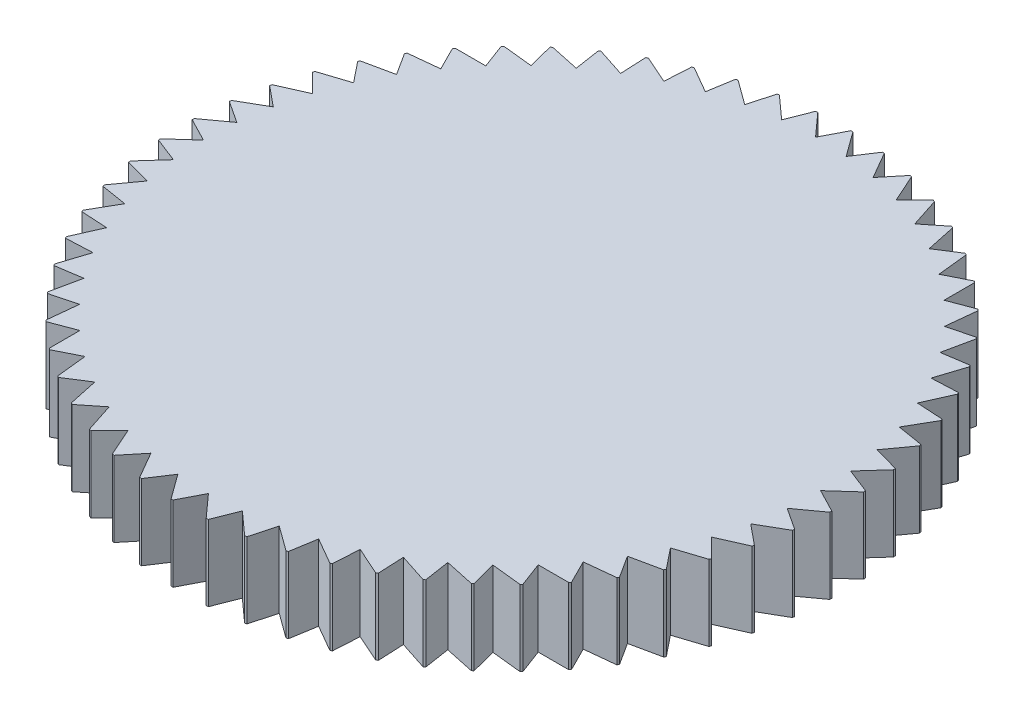
from build123d import *

# Parameters (mm, degrees)
Y_KSEKLIK_EKSTR_ZYON1_DEPTH = 3


with BuildPart() as part:
    # Çizim1 → Yükseklik-Ekstrüzyon1 (new body)
    with BuildSketch(Plane(origin=(0, 0, 0), x_dir=(1, 0, 0), z_dir=(0, 1, 0))):
        with BuildLine():
            ThreePointArc((-9.087504767, -9.407638232), (-9.059200833, -9.43489694), (-9.030815135, -9.462070492))
            Line((-9.030815135, -9.462070492), (-8.054356498, -9.094039392))
            Line((-8.054356498, -9.094039392), (-8.054356498, -10.306005114))
            ThreePointArc((-8.054356498, -10.306005114), (-8.023358305, -10.330155929), (-7.992287697, -10.354213508))
            Line((-7.992287697, -10.354213508), (-7.059647927, -9.8861308))
            Line((-7.059647927, -9.8861308), (-6.932963013, -11.091457247))
            ThreePointArc((-6.932963013, -11.091457247), (-6.899610184, -11.112235567), (-6.866195083, -11.132913594))
            Line((-6.866195083, -11.132913594), (-5.987592377, -10.56990769))
            Line((-5.987592377, -10.56990769), (-5.735610535, -11.755389053))
            ThreePointArc((-5.735610535, -11.755389053), (-5.70026849, -11.772567228), (-5.664874998, -11.789639149))
            Line((-5.664874998, -11.789639149), (-4.849935512, -11.13787846))
            Line((-4.849935512, -11.13787846), (-4.475417507, -12.290526357))
            ThreePointArc((-4.475417507, -12.290526357), (-4.438473462, -12.303916178), (-4.401489357, -12.31719495))
            Line((-4.401489357, -12.31719495), (-3.659141738, -11.583820302))
            Line((-3.659141738, -11.583820302), (-3.166190869, -12.691006082))
            ThreePointArc((-3.166190869, -12.691006082), (-3.12804959, -12.700460848), (-3.089880078, -12.709800986))
            Line((-3.089880078, -12.709800986), (-2.428257642, -11.902847385))
            Line((-2.428257642, -11.902847385), (-1.822274781, -12.952440489))
            ThreePointArc((-1.822274781, -12.952440489), (-1.783354152, -12.957856612), (-1.744417426, -12.963155783))
            Line((-1.744417426, -12.963155783), (-1.170769047, -12.091464382))
            Line((-1.170769047, -12.091464382), (-0.458393469, -13.071965247))
            ThreePointArc((-0.458393469, -13.071965247), (-0.419119912, -13.073283386), (-0.379842572, -13.074483532))
            Line((-0.379842572, -13.074483532), (0.099546739, -12.147604764))
            Line((0.099546739, -12.147604764), (0.910510097, -13.048270819))
            ThreePointArc((0.910510097, -13.048270819), (0.949706293, -13.045476532), (0.988893917, -13.042564503))
            Line((0.988893917, -13.042564503), (1.36877187, -12.070653446))
            Line((1.36877187, -12.070653446), (2.269437925, -12.881616805))
            ThreePointArc((2.269437925, -12.881616805), (2.308127317, -12.874740708), (2.346795877, -12.867748409))
            Line((2.346795877, -12.867748409), (2.62300045, -11.861453524))
            Line((2.62300045, -11.861453524), (3.603501315, -12.573829101))
            ThreePointArc((3.603501315, -12.573829101), (3.641260015, -12.562946529), (3.67898585, -12.55195057))
            Line((3.67898585, -12.55195057), (3.848490888, -11.522297034))
            Line((3.848490888, -11.522297034), (4.898083992, -12.128279895))
            ThreePointArc((4.898083992, -12.128279895), (4.934498307, -12.11351008), (4.970868085, -12.098630934))
            Line((4.970868085, -12.098630934), (5.031816454, -11.056899847))
            Line((5.031816454, -11.056899847), (6.139002234, -11.549850716))
            ThreePointArc((6.139002234, -11.549850716), (6.173673202, -11.531355479), (6.208288449, -11.512756166))
            Line((6.208288449, -11.512756166), (6.160012387, -10.470360951))
            Line((6.160012387, -10.470360951), (7.312660284, -10.844878956))
            ThreePointArc((7.312660284, -10.844878956), (7.345208042, -10.822860935), (7.377689505, -10.800745232))
            Line((7.377689505, -10.800745232), (7.220717935, -9.76910659))
            Line((7.220717935, -9.76910659), (8.406199298, -10.021088432))
            ThreePointArc((8.406199298, -10.021088432), (8.436267245, -9.995788861), (8.466259051, -9.970399073))
            Line((8.466259051, -9.970399073), (8.202311786, -8.960819852))
            Line((8.202311786, -8.960819852), (9.407638232, -9.087504767))
            ThreePointArc((9.407638232, -9.087504767), (9.43489694, -9.059200833), (9.462070492, -9.030815135))
            Line((9.462070492, -9.030815135), (9.094039392, -8.054356498))
            Line((9.094039392, -8.054356498), (10.306005114, -8.054356498))
            ThreePointArc((10.306005114, -8.054356498), (10.330155929, -8.023358305), (10.354213508, -7.992287697))
            Line((10.354213508, -7.992287697), (9.8861308, -7.059647927))
            Line((9.8861308, -7.059647927), (11.091457247, -6.932963013))
            ThreePointArc((11.091457247, -6.932963013), (11.112235567, -6.899610184), (11.132913594, -6.866195083))
            Line((11.132913594, -6.866195083), (10.56990769, -5.987592377))
            Line((10.56990769, -5.987592377), (11.755389053, -5.735610535))
            ThreePointArc((11.755389053, -5.735610535), (11.772567228, -5.70026849), (11.789639149, -5.664874998))
            Line((11.789639149, -5.664874998), (11.13787846, -4.849935512))
            Line((11.13787846, -4.849935512), (12.290526357, -4.475417507))
            ThreePointArc((12.290526357, -4.475417507), (12.303916178, -4.438473462), (12.31719495, -4.401489357))
            Line((12.31719495, -4.401489357), (11.583820302, -3.659141738))
            Line((11.583820302, -3.659141738), (12.691006082, -3.166190869))
            ThreePointArc((12.691006082, -3.166190869), (12.700460848, -3.12804959), (12.709800986, -3.089880078))
            Line((12.709800986, -3.089880078), (11.902847385, -2.428257642))
            Line((11.902847385, -2.428257642), (12.952440489, -1.822274781))
            ThreePointArc((12.952440489, -1.822274781), (12.957856612, -1.783354152), (12.963155783, -1.744417426))
            Line((12.963155783, -1.744417426), (12.091464382, -1.170769047))
            Line((12.091464382, -1.170769047), (13.071965247, -0.458393469))
            ThreePointArc((13.071965247, -0.458393469), (13.073283386, -0.419119912), (13.074483532, -0.379842572))
            Line((13.074483532, -0.379842572), (12.147604764, 0.099546739))
            Line((12.147604764, 0.099546739), (13.048270819, 0.910510097))
            ThreePointArc((13.048270819, 0.910510097), (13.045476532, 0.949706293), (13.042564503, 0.988893917))
            Line((13.042564503, 0.988893917), (12.070653446, 1.36877187))
            Line((12.070653446, 1.36877187), (12.881616805, 2.269437925))
            ThreePointArc((12.881616805, 2.269437925), (12.874740708, 2.308127317), (12.867748409, 2.346795877))
            Line((12.867748409, 2.346795877), (11.861453524, 2.62300045))
            Line((11.861453524, 2.62300045), (12.573829101, 3.603501315))
            ThreePointArc((12.573829101, 3.603501315), (12.562946529, 3.641260015), (12.55195057, 3.67898585))
            Line((12.55195057, 3.67898585), (11.522297034, 3.848490888))
            Line((11.522297034, 3.848490888), (12.128279895, 4.898083992))
            ThreePointArc((12.128279895, 4.898083992), (12.11351008, 4.934498307), (12.098630934, 4.970868085))
            Line((12.098630934, 4.970868085), (11.056899847, 5.031816454))
            Line((11.056899847, 5.031816454), (11.549850716, 6.139002234))
            ThreePointArc((11.549850716, 6.139002234), (11.531355479, 6.173673202), (11.512756166, 6.208288449))
            Line((11.512756166, 6.208288449), (10.470360951, 6.160012387))
            Line((10.470360951, 6.160012387), (10.844878956, 7.312660284))
            ThreePointArc((10.844878956, 7.312660284), (10.822860935, 7.345208042), (10.800745232, 7.377689505))
            Line((10.800745232, 7.377689505), (9.76910659, 7.220717935))
            Line((9.76910659, 7.220717935), (10.021088432, 8.406199298))
            ThreePointArc((10.021088432, 8.406199298), (9.995788861, 8.436267245), (9.970399073, 8.466259051))
            Line((9.970399073, 8.466259051), (8.960819852, 8.202311786))
            Line((8.960819852, 8.202311786), (9.087504767, 9.407638232))
            ThreePointArc((9.087504767, 9.407638232), (9.059200833, 9.43489694), (9.030815135, 9.462070492))
            Line((9.030815135, 9.462070492), (8.054356498, 9.094039392))
            Line((8.054356498, 9.094039392), (8.054356498, 10.306005114))
            ThreePointArc((8.054356498, 10.306005114), (8.023358305, 10.330155929), (7.992287697, 10.354213508))
            Line((7.992287697, 10.354213508), (7.059647927, 9.8861308))
            Line((7.059647927, 9.8861308), (6.932963013, 11.091457247))
            ThreePointArc((6.932963013, 11.091457247), (6.899610184, 11.112235567), (6.866195083, 11.132913594))
            Line((6.866195083, 11.132913594), (5.987592377, 10.56990769))
            Line((5.987592377, 10.56990769), (5.735610535, 11.755389053))
            ThreePointArc((5.735610535, 11.755389053), (5.70026849, 11.772567228), (5.664874998, 11.789639149))
            Line((5.664874998, 11.789639149), (4.849935512, 11.13787846))
            Line((4.849935512, 11.13787846), (4.475417507, 12.290526357))
            ThreePointArc((4.475417507, 12.290526357), (4.438473462, 12.303916178), (4.401489357, 12.31719495))
            Line((4.401489357, 12.31719495), (3.659141738, 11.583820302))
            Line((3.659141738, 11.583820302), (3.166190869, 12.691006082))
            ThreePointArc((3.166190869, 12.691006082), (3.12804959, 12.700460848), (3.089880078, 12.709800986))
            Line((3.089880078, 12.709800986), (2.428257642, 11.902847385))
            Line((2.428257642, 11.902847385), (1.822274781, 12.952440489))
            ThreePointArc((1.822274781, 12.952440489), (1.783354152, 12.957856612), (1.744417426, 12.963155783))
            Line((1.744417426, 12.963155783), (1.170769047, 12.091464382))
            Line((1.170769047, 12.091464382), (0.458393469, 13.071965247))
            ThreePointArc((0.458393469, 13.071965247), (0.419119912, 13.073283386), (0.379842572, 13.074483532))
            Line((0.379842572, 13.074483532), (-0.099546739, 12.147604764))
            Line((-0.099546739, 12.147604764), (-0.910510097, 13.048270819))
            ThreePointArc((-0.910510097, 13.048270819), (-0.949706293, 13.045476532), (-0.988893917, 13.042564503))
            Line((-0.988893917, 13.042564503), (-1.36877187, 12.070653446))
            Line((-1.36877187, 12.070653446), (-2.269437925, 12.881616805))
            ThreePointArc((-2.269437925, 12.881616805), (-2.308127317, 12.874740708), (-2.346795877, 12.867748409))
            Line((-2.346795877, 12.867748409), (-2.62300045, 11.861453524))
            Line((-2.62300045, 11.861453524), (-3.603501315, 12.573829101))
            ThreePointArc((-3.603501315, 12.573829101), (-3.641260015, 12.562946529), (-3.67898585, 12.55195057))
            Line((-3.67898585, 12.55195057), (-3.848490888, 11.522297034))
            Line((-3.848490888, 11.522297034), (-4.898083992, 12.128279895))
            ThreePointArc((-4.898083992, 12.128279895), (-4.934498307, 12.11351008), (-4.970868085, 12.098630934))
            Line((-4.970868085, 12.098630934), (-5.031816454, 11.056899847))
            Line((-5.031816454, 11.056899847), (-6.139002234, 11.549850716))
            ThreePointArc((-6.139002234, 11.549850716), (-6.173673202, 11.531355479), (-6.208288449, 11.512756166))
            Line((-6.208288449, 11.512756166), (-6.160012387, 10.470360951))
            Line((-6.160012387, 10.470360951), (-7.312660284, 10.844878956))
            ThreePointArc((-7.312660284, 10.844878956), (-7.345208042, 10.822860935), (-7.377689505, 10.800745232))
            Line((-7.377689505, 10.800745232), (-7.220717935, 9.76910659))
            Line((-7.220717935, 9.76910659), (-8.406199298, 10.021088432))
            ThreePointArc((-8.406199298, 10.021088432), (-8.436267245, 9.995788861), (-8.466259051, 9.970399073))
            Line((-8.466259051, 9.970399073), (-8.202311786, 8.960819852))
            Line((-8.202311786, 8.960819852), (-9.407638232, 9.087504767))
            ThreePointArc((-9.407638232, 9.087504767), (-9.43489694, 9.059200833), (-9.462070492, 9.030815135))
            Line((-9.462070492, 9.030815135), (-9.094039392, 8.054356498))
            Line((-9.094039392, 8.054356498), (-10.306005114, 8.054356498))
            ThreePointArc((-10.306005114, 8.054356498), (-10.330155929, 8.023358305), (-10.354213508, 7.992287697))
            Line((-10.354213508, 7.992287697), (-9.8861308, 7.059647927))
            Line((-9.8861308, 7.059647927), (-11.091457247, 6.932963013))
            ThreePointArc((-11.091457247, 6.932963013), (-11.112235567, 6.899610184), (-11.132913594, 6.866195083))
            Line((-11.132913594, 6.866195083), (-10.56990769, 5.987592377))
            Line((-10.56990769, 5.987592377), (-11.755389053, 5.735610535))
            ThreePointArc((-11.755389053, 5.735610535), (-11.772567228, 5.70026849), (-11.789639149, 5.664874998))
            Line((-11.789639149, 5.664874998), (-11.13787846, 4.849935512))
            Line((-11.13787846, 4.849935512), (-12.290526357, 4.475417507))
            ThreePointArc((-12.290526357, 4.475417507), (-12.303916178, 4.438473462), (-12.31719495, 4.401489357))
            Line((-12.31719495, 4.401489357), (-11.583820302, 3.659141738))
            Line((-11.583820302, 3.659141738), (-12.691006082, 3.166190869))
            ThreePointArc((-12.691006082, 3.166190869), (-12.700460848, 3.12804959), (-12.709800986, 3.089880078))
            Line((-12.709800986, 3.089880078), (-11.902847385, 2.428257642))
            Line((-11.902847385, 2.428257642), (-12.952440489, 1.822274781))
            ThreePointArc((-12.952440489, 1.822274781), (-12.957856612, 1.783354152), (-12.963155783, 1.744417426))
            Line((-12.963155783, 1.744417426), (-12.091464382, 1.170769047))
            Line((-12.091464382, 1.170769047), (-13.071965247, 0.458393469))
            ThreePointArc((-13.071965247, 0.458393469), (-13.073283386, 0.419119912), (-13.074483532, 0.379842572))
            Line((-13.074483532, 0.379842572), (-12.147604764, -0.099546739))
            Line((-12.147604764, -0.099546739), (-13.048270819, -0.910510097))
            ThreePointArc((-13.048270819, -0.910510097), (-13.045476532, -0.949706293), (-13.042564503, -0.988893917))
            Line((-13.042564503, -0.988893917), (-12.070653446, -1.36877187))
            Line((-12.070653446, -1.36877187), (-12.881616805, -2.269437925))
            ThreePointArc((-12.881616805, -2.269437925), (-12.874740708, -2.308127317), (-12.867748409, -2.346795877))
            Line((-12.867748409, -2.346795877), (-11.861453524, -2.62300045))
            Line((-11.861453524, -2.62300045), (-12.573829101, -3.603501315))
            ThreePointArc((-12.573829101, -3.603501315), (-12.562946529, -3.641260015), (-12.55195057, -3.67898585))
            Line((-12.55195057, -3.67898585), (-11.522297034, -3.848490888))
            Line((-11.522297034, -3.848490888), (-12.128279895, -4.898083992))
            ThreePointArc((-12.128279895, -4.898083992), (-12.11351008, -4.934498307), (-12.098630934, -4.970868085))
            Line((-12.098630934, -4.970868085), (-11.056899847, -5.031816454))
            Line((-11.056899847, -5.031816454), (-11.549850716, -6.139002234))
            ThreePointArc((-11.549850716, -6.139002234), (-11.531355479, -6.173673202), (-11.512756166, -6.208288449))
            Line((-11.512756166, -6.208288449), (-10.470360951, -6.160012387))
            Line((-10.470360951, -6.160012387), (-10.844878956, -7.312660284))
            ThreePointArc((-10.844878956, -7.312660284), (-10.822860935, -7.345208042), (-10.800745232, -7.377689505))
            Line((-10.800745232, -7.377689505), (-9.76910659, -7.220717935))
            Line((-9.76910659, -7.220717935), (-10.021088432, -8.406199298))
            ThreePointArc((-10.021088432, -8.406199298), (-9.995788861, -8.436267245), (-9.970399073, -8.466259051))
            Line((-9.970399073, -8.466259051), (-8.960819852, -8.202311786))
            Line((-8.960819852, -8.202311786), (-9.087504767, -9.407638232))
        make_face()
    extrude(amount=Y_KSEKLIK_EKSTR_ZYON1_DEPTH)


solid = part.part
